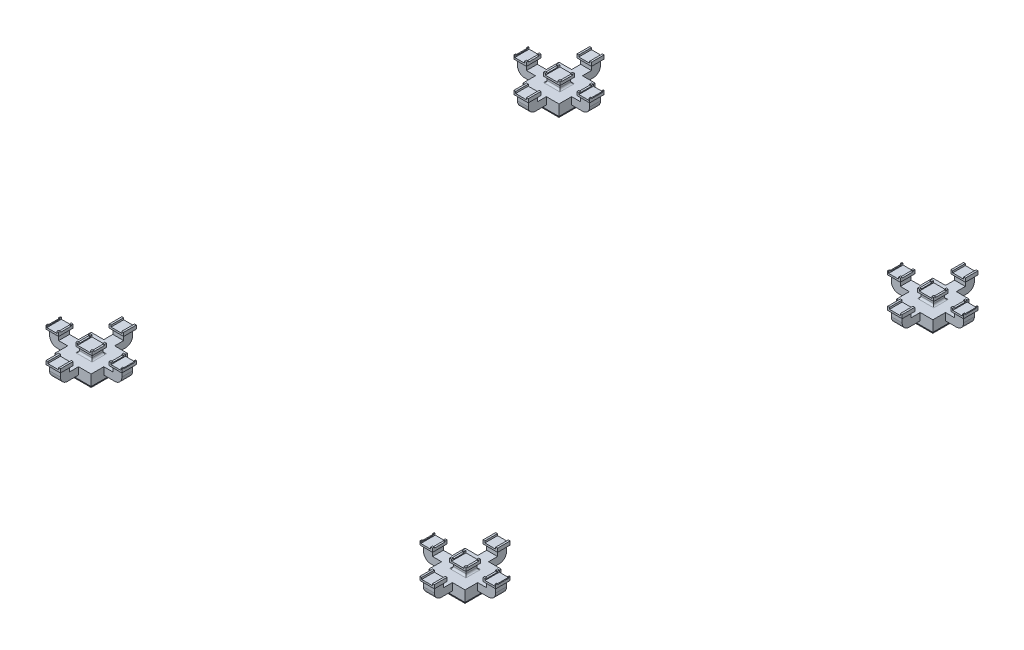
from build123d import *

# Parameters (mm, degrees)
SKETCH_1_W               = 50
SKETCH_1_H               = 50
EXTRUDE_1_DEPTH          = 70
SKETCH_2_W               = 150
SKETCH_2_H               = 150
SKETCH_3_W               = 200
SKETCH_3_H               = 200
SKETCH_4_W               = 200
SKETCH_4_H               = 200
EXTRUDE_2_DEPTH          = 20
SKETCH_5_W               = 70
SKETCH_5_H               = 70
EXTRUDE_3_DEPTH          = 40
SKETCH_6_W               = 400
SKETCH_6_H               = 60
EXTRUDE_4_DEPTH          = 40
SKETCH_7_W               = 50
SKETCH_7_H               = 60
SKETCH_7_W_2             = 70
EXTRUDE_6_DEPTH          = 20
SKETCH_8_W               = 65
SKETCH_8_H               = 60
CUT_EXTRUDE_1_DEPTH      = 20
FILLET_1_R               = 40
SKETCH_10_W              = 50
SKETCH_10_H              = 60
SKETCH_9_W               = 70
SKETCH_9_H               = 80
SKETCH_12_W              = 70
SKETCH_12_H              = 80
EXTRUDE_7_DEPTH          = 10
SKETCH_13_W              = 10
SKETCH_13_H              = 80
SKETCH_13_W_2            = 5
EXTRUDE_8_DEPTH          = 10
SKETCH_15_W              = 60
SKETCH_15_H              = 400
EXTRUDE_9_DEPTH          = 40
SKETCH_16_W              = 60
SKETCH_16_H              = 50
EXTRUDE_10_DEPTH         = 20
SKETCH_18_W              = 80
SKETCH_18_H              = 70
SKETCH_17_W              = 60
SKETCH_17_H              = 50
SKETCH_19_W              = 80
SKETCH_19_H              = 70
EXTRUDE_12_DEPTH         = 10
SKETCH_20_W              = 10
SKETCH_20_H              = 70
EXTRUDE_13_DEPTH         = 10
FILLET_3_R               = 10
SKETCH_21_W              = 60
SKETCH_21_H              = 60
EXTRUDE_14_DEPTH         = 20
FILLET_4_R               = 10
SKETCH_22_W              = 70
SKETCH_22_H              = 60
SKETCH_23_W              = 90
SKETCH_23_H              = 80
EXTRUDE_15_DEPTH         = 10
SKETCH_25_W              = 10
SKETCH_25_H              = 80
EXTRUDE_16_DEPTH         = 10
SKETCH_26_W              = 420
SKETCH_26_H              = 60
CUT_EXTRUDE_2_DEPTH      = 5
FILLET_5_R               = 40
SCALE_1_SCALE            = 2
SKETCH_30_W              = 100
SKETCH_30_H              = 100
SKETCH_30_W_2            = 80
SKETCH_30_H_2            = 80
CUT_EXTRUDE_4_DEPTH      = 140
SKETCH_31_W              = 80
SKETCH_31_H              = 40
CUT_EXTRUDE_5_DEPTH      = 140
PATTERN_LINEAR_1_COUNT   = 2
PATTERN_LINEAR_1_PITCH   = 5180
PATTERN_LINEAR_1_2_COUNT = 2
PATTERN_LINEAR_1_2_PITCH = 4140


with BuildPart() as part:
    # 草图1 → 凸台-拉伸1 (new body)
    with BuildSketch(Plane(origin=(0, 0, 0), x_dir=(1, 0, 0), z_dir=(0, 1, 0))):
        with Locations((25, 25)):
            Rectangle(SKETCH_1_W, SKETCH_1_H)
    extrude(amount=EXTRUDE_1_DEPTH)

    # 草图2 → 放样2 section 0
    with BuildSketch(Plane(origin=(0, 70, 0), x_dir=(1, 0, 0), z_dir=(0, 1, 0))):
        with Locations((25, 25)):
            Rectangle(SKETCH_2_W, SKETCH_2_H)
    # 草图3 → 放样2 section 1
    with BuildSketch(Plane(origin=(0, 100, 0), x_dir=(1, 0, 0), z_dir=(0, 1, 0))):
        with Locations((25, 25)):
            Rectangle(SKETCH_3_W, SKETCH_3_H)
    loft()

    # 草图4 → 凸台-拉伸2 (add)
    with BuildSketch(Plane(origin=(0, 100, 0), x_dir=(1, 0, 0), z_dir=(0, 1, 0))):
        with Locations((25, 25)):
            Rectangle(SKETCH_4_W, SKETCH_4_H)
    extrude(amount=EXTRUDE_2_DEPTH)

    # 草图5 → 凸台-拉伸3 (add)
    with BuildSketch(Plane(origin=(0, 120, 0), x_dir=(1, 0, 0), z_dir=(0, 1, 0))):
        with Locations((-40, -40)):
            Rectangle(SKETCH_5_W, SKETCH_5_H)
        with Locations((90, -40)):
            Rectangle(SKETCH_5_W, SKETCH_5_H)
        with Locations((90, 90)):
            Rectangle(SKETCH_5_W, SKETCH_5_H)
        with Locations((-40, 90)):
            Rectangle(SKETCH_5_W, SKETCH_5_H)
    extrude(amount=EXTRUDE_3_DEPTH)

    # 草图6 → 凸台-拉伸4 (add)
    with BuildSketch(Plane(origin=(0, 120, 0), x_dir=(1, 0, 0), z_dir=(0, 1, 0))):
        with Locations((25, 25)):
            Rectangle(SKETCH_6_W, SKETCH_6_H)
    extrude(amount=EXTRUDE_4_DEPTH)

    # 草图7 → 凸台-拉伸6 (add)
    with BuildSketch(Plane(origin=(0, 160, 0), x_dir=(1, 0, 0), z_dir=(0, 1, 0))):
        with Locations((200, 25)):
            Rectangle(SKETCH_7_W, SKETCH_7_H)
        with Locations((-150, 25)):
            Rectangle(SKETCH_7_W, SKETCH_7_H)
        with Locations((90, 25)):
            Rectangle(SKETCH_7_W_2, SKETCH_7_H)
        with Locations((-40, 25)):
            Rectangle(SKETCH_7_W_2, SKETCH_7_H)
    extrude(amount=EXTRUDE_6_DEPTH)

    # 草图8 → 切除-拉伸1 (cut)
    with BuildSketch(Plane(origin=(0, 180, 0), x_dir=(1, 0, 0), z_dir=(0, 1, 0))):
        with Locations((-42.5, 25)):
            Rectangle(SKETCH_8_W, SKETCH_8_H)
        with Locations((92.5, 25)):
            Rectangle(SKETCH_8_W, SKETCH_8_H)
    extrude(amount=-CUT_EXTRUDE_1_DEPTH, mode=Mode.SUBTRACT)

    # 圆角1
    fillet_1_edges = [part.edges().sort_by_distance(p)[0] for p in [
        (225, 120, -25),
        (-175, 120, -25),
    ]]
    fillet(fillet_1_edges, radius=FILLET_1_R)

    # 草图10 → 放样3 section 0
    with BuildSketch(Plane(origin=(0, 180, 0), x_dir=(1, 0, 0), z_dir=(0, 1, 0))):
        with Locations((200, 25)):
            Rectangle(SKETCH_10_W, SKETCH_10_H)
    # 草图9 → 放样3 section 1
    with BuildSketch(Plane(origin=(0, 190, 0), x_dir=(1, 0, 0), z_dir=(0, 1, 0))):
        with Locations((200, 25)):
            Rectangle(SKETCH_9_W, SKETCH_9_H)
    loft_3 = loft()

    # 草图12 → 凸台-拉伸7 (add)
    with BuildSketch(Plane(origin=(0, 190, 0), x_dir=(1, 0, 0), z_dir=(0, 1, 0))):
        with Locations((200, 25)):
            Rectangle(SKETCH_12_W, SKETCH_12_H)
    extrude_7 = extrude(amount=EXTRUDE_7_DEPTH)

    # 草图13 → 凸台-拉伸8 (add)
    with BuildSketch(Plane(origin=(0, 200, 0), x_dir=(1, 0, 0), z_dir=(0, 1, 0))):
        with Locations((170, 25)):
            Rectangle(SKETCH_13_W, SKETCH_13_H)
        with Locations((232.5, 25)):
            Rectangle(SKETCH_13_W_2, SKETCH_13_H)
    extrude_8 = extrude(amount=EXTRUDE_8_DEPTH)

    # 镜向2: 放样3, 凸台-拉伸7, 凸台-拉伸8 across plane
    add(loft_3.mirror(Plane(origin=(25, 0, 0), x_dir=(0, 0, 1), z_dir=(1, 0, 0))))
    add(extrude_7.mirror(Plane(origin=(25, 0, 0), x_dir=(0, 0, 1), z_dir=(1, 0, 0))))
    add(extrude_8.mirror(Plane(origin=(25, 0, 0), x_dir=(0, 0, 1), z_dir=(1, 0, 0))))

    # 草图15 → 凸台-拉伸9 (add)
    with BuildSketch(Plane(origin=(0, 120, 0), x_dir=(1, 0, 0), z_dir=(0, 1, 0))):
        with Locations((25, 25)):
            Rectangle(SKETCH_15_W, SKETCH_15_H)
    extrude(amount=EXTRUDE_9_DEPTH)

    # 草图16 → 凸台-拉伸10 (add)
    with BuildSketch(Plane(origin=(0, 160, 0), x_dir=(1, 0, 0), z_dir=(0, 1, 0))):
        with Locations((25, -150)):
            Rectangle(SKETCH_16_W, SKETCH_16_H)
        with Locations((25, 200)):
            Rectangle(SKETCH_16_W, SKETCH_16_H)
    extrude(amount=EXTRUDE_10_DEPTH)

    # 草图18 → 放样4 section 0
    with BuildSketch(Plane(origin=(0, 190, 0), x_dir=(1, 0, 0), z_dir=(0, 1, 0))):
        with Locations((25, -150)):
            Rectangle(SKETCH_18_W, SKETCH_18_H)
    # 草图17 → 放样4 section 1
    with BuildSketch(Plane(origin=(0, 180, 0), x_dir=(1, 0, 0), z_dir=(0, 1, 0))):
        with Locations((25, -150)):
            Rectangle(SKETCH_17_W, SKETCH_17_H)
    loft_4 = loft()

    # 草图19 → 凸台-拉伸12 (add)
    with BuildSketch(Plane(origin=(0, 190, 0), x_dir=(1, 0, 0), z_dir=(0, 1, 0))):
        with Locations((25, -150)):
            Rectangle(SKETCH_19_W, SKETCH_19_H)
    extrude_12 = extrude(amount=EXTRUDE_12_DEPTH)

    # 草图20 → 凸台-拉伸13 (add)
    with BuildSketch(Plane(origin=(0, 200, 0), x_dir=(1, 0, 0), z_dir=(0, 1, 0))):
        with Locations((-10, -150)):
            Rectangle(SKETCH_20_W, SKETCH_20_H)
        with Locations((60, -150)):
            Rectangle(SKETCH_20_W, SKETCH_20_H)
    extrude_13 = extrude(amount=EXTRUDE_13_DEPTH)

    # 镜向3: 放样4, 凸台-拉伸12, 凸台-拉伸13 across plane
    add(loft_4.mirror(Plane.XY.offset(-25)))
    add(extrude_12.mirror(Plane.XY.offset(-25)))
    add(extrude_13.mirror(Plane.XY.offset(-25)))

    # 圆角3
    fillet_3_edges = [part.edges().sort_by_distance(p)[0] for p in [
        (-10, 160, -25),
        (60, 160, -25),
    ]]
    fillet(fillet_3_edges, radius=FILLET_3_R)

    # 草图21 → 凸台-拉伸14 (add)
    with BuildSketch(Plane(origin=(0, 160, 0), x_dir=(1, 0, 0), z_dir=(0, 1, 0))):
        with Locations((25, 25)):
            Rectangle(SKETCH_21_W, SKETCH_21_H)
    extrude(amount=EXTRUDE_14_DEPTH)

    # 圆角4
    fillet_4_edges = [part.edges().sort_by_distance(p)[0] for p in [
        (25, 160, -55),
        (25, 160, 5),
    ]]
    fillet(fillet_4_edges, radius=FILLET_4_R)

    # 草图22 → 放样5 section 0
    with BuildSketch(Plane(origin=(0, 180, 0), x_dir=(1, 0, 0), z_dir=(0, 1, 0))):
        with Locations((25, 25)):
            Rectangle(SKETCH_22_W, SKETCH_22_H)
    # 草图23 → 放样5 section 1
    with BuildSketch(Plane(origin=(0, 190, 0), x_dir=(1, 0, 0), z_dir=(0, 1, 0))):
        with Locations((25, 25)):
            Rectangle(SKETCH_23_W, SKETCH_23_H)
    loft()

    # 草图24 → 凸台-拉伸15 (add)
    with BuildSketch(Plane(origin=(0, 190, 0), x_dir=(1, 0, 0), z_dir=(0, 1, 0))):
        Polygon((-20, 65), (-20, -15), (-10, -15), (60, -15), (70, -15), (70, 65), (60, 65), (-10, 65), align=None)
    extrude(amount=EXTRUDE_15_DEPTH)

    # 草图25 → 凸台-拉伸16 (add)
    with BuildSketch(Plane(origin=(0, 200, 0), x_dir=(1, 0, 0), z_dir=(0, 1, 0))):
        with Locations((-15, 25)):
            Rectangle(SKETCH_25_W, SKETCH_25_H)
        with Locations((65, 25)):
            Rectangle(SKETCH_25_W, SKETCH_25_H)
    extrude(amount=EXTRUDE_16_DEPTH)

    # 草图26 → 切除-拉伸2 (cut)
    with BuildSketch(Plane(origin=(0, 210, 0), x_dir=(1, 0, 0), z_dir=(0, 1, 0))):
        with Locations((25, 25)):
            Rectangle(SKETCH_26_W, SKETCH_26_H)
    extrude(amount=-CUT_EXTRUDE_2_DEPTH, mode=Mode.SUBTRACT)

    # 圆角5
    fillet_5_edges = [part.edges().sort_by_distance(p)[0] for p in [
        (25, 120, -225),
        (25, 120, 175),
    ]]
    fillet(fillet_5_edges, radius=FILLET_5_R)


with BuildPart() as part_1:
    # 缩放比例1: scaled about (0, 0, 0)
    add(part.part.scale(SCALE_1_SCALE))

    # 草图30 → 切除-拉伸4 (cut)
    with BuildSketch(Plane.XZ):
        with Locations((50, -50)):
            Rectangle(SKETCH_30_W, SKETCH_30_H)
        with Locations((50, -50)):
            Rectangle(SKETCH_30_W_2, SKETCH_30_H_2, mode=Mode.SUBTRACT)
    extrude(amount=-CUT_EXTRUDE_4_DEPTH, mode=Mode.SUBTRACT)

    # 草图31 → 切除-拉伸5 (cut)
    with BuildSketch(Plane.ZY.offset(-10)):
        with Locations((-50, 20)):
            Rectangle(SKETCH_31_W, SKETCH_31_H)
    extrude(amount=-CUT_EXTRUDE_5_DEPTH, mode=Mode.SUBTRACT)


with BuildPart() as pattern_linear_1_1:
    # 阵列(线性)1: pattern copy
    add(part_1.part.moved(Location(Vector(0, 0, -1) * (1 * PATTERN_LINEAR_1_PITCH))))


with BuildPart() as pattern_linear_1_2_1:
    # Pattern Linear 1 2: pattern copy
    add(part_1.part.moved(Location(Vector(1, 0, 0) * (1 * PATTERN_LINEAR_1_2_PITCH))))


with BuildPart() as pattern_linear_1_2_2:
    # Pattern Linear 1 2: pattern copy
    add(pattern_linear_1_1.part.moved(Location(Vector(1, 0, 0) * (1 * PATTERN_LINEAR_1_2_PITCH))))


solid = Compound([part_1.part, pattern_linear_1_1.part, pattern_linear_1_2_1.part, pattern_linear_1_2_2.part])
